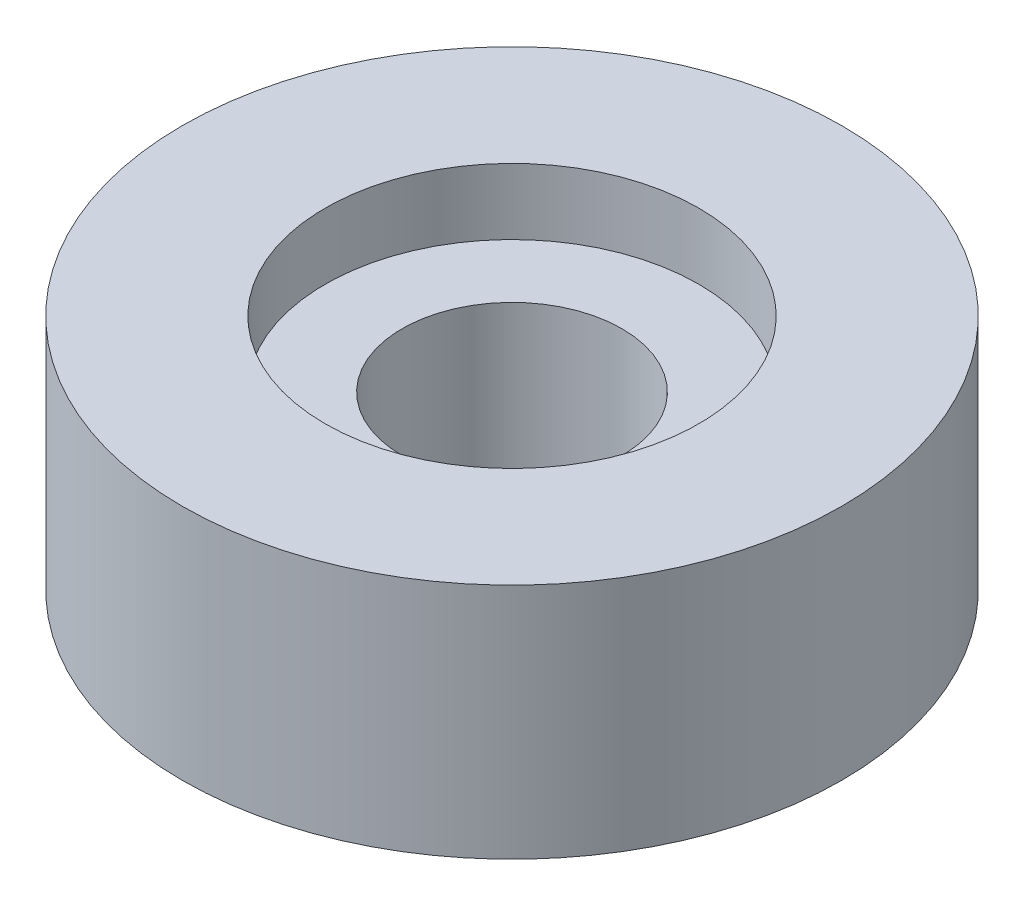
from build123d import *

# Parameters (mm, degrees)
SKETCH1_R           = 7.5
SKETCH1_R_2         = 2.5
BOSS_EXTRUDE1_DEPTH = 3.9
SKETCH2_R           = 7.5
SKETCH2_R_2         = 4.25
BOSS_EXTRUDE2_DEPTH = 1.5


with BuildPart() as part:
    # Sketch1 → Boss-Extrude1 (new body)
    with BuildSketch(Plane(origin=(0, 0, 0), x_dir=(1, 0, 0), z_dir=(0, 1, 0))):
        Circle(SKETCH1_R)
        Circle(SKETCH1_R_2, mode=Mode.SUBTRACT)
    extrude(amount=BOSS_EXTRUDE1_DEPTH)

    # Sketch2 → Boss-Extrude2 (add)
    with BuildSketch(Plane(origin=(0, 3.9, 0), x_dir=(1, 0, 0), z_dir=(0, 1, 0))):
        Circle(SKETCH2_R)
        Circle(SKETCH2_R_2, mode=Mode.SUBTRACT)
    extrude(amount=BOSS_EXTRUDE2_DEPTH)


solid = part.part
